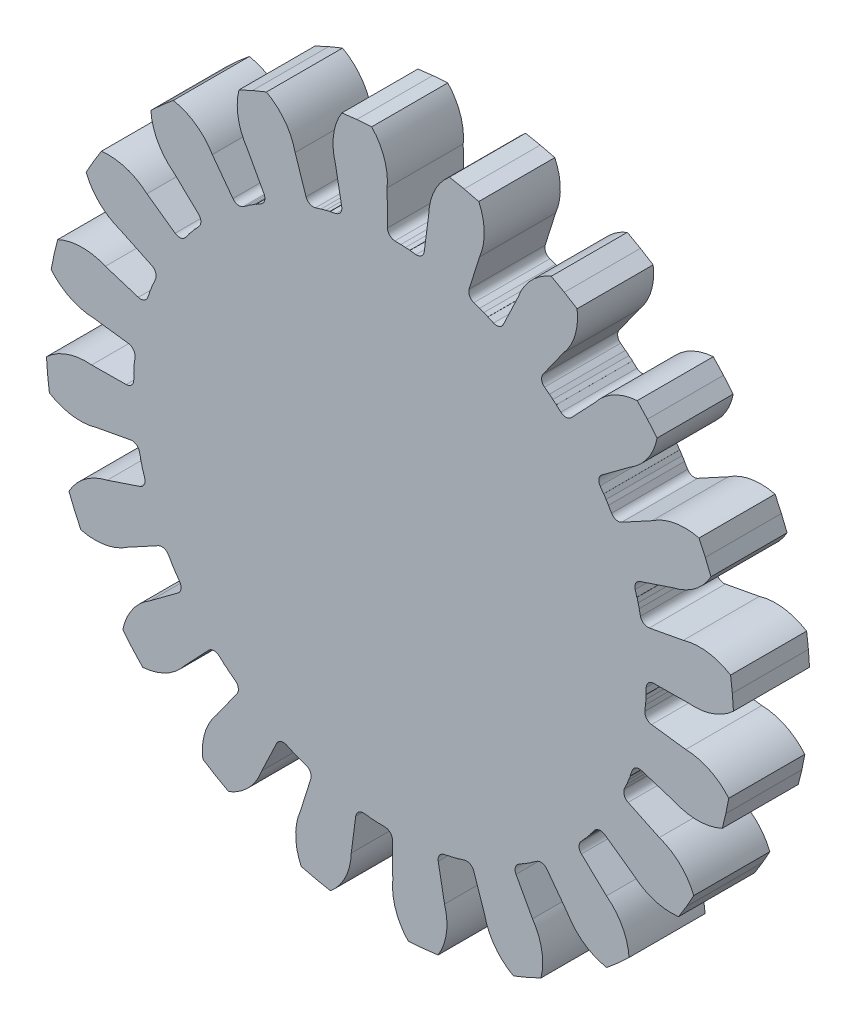
from build123d import *

# Parameters (mm, degrees)
BOSS_EXTRUDE1_DEPTH      = 10
FILLET2_R                = 1
CIRPATTERN1_COUNT        = 20
FILLET2_OF_CIRPATTERN1_R = 1


with BuildPart() as part:
    # Sketch1 → Boss-Extrude1 (new body)
    with BuildSketch(Plane.XY):
        with BuildLine():
            Line((38.885886089, -5.091685204), (33.432437269, -4.377615204))
            Line((33.432437269, -4.377615204), (33.686751056, -1.447128155))
            Line((33.686751056, -1.447128155), (0, 0))
            Line((0, 0), (31.160244407, -12.881403073))
            Line((31.160244407, -12.881403073), (32.164358522, -10.1165912))
            Line((32.164358522, -10.1165912), (37.410960246, -11.766794321))
            ThreePointArc((37.410960246, -11.766794321), (40.558227871, -12.393780689), (43.685256176, -11.672601527))
            Line((43.685256176, -11.672601527), (44.152829219, -9.755967686))
            Line((44.152829219, -9.755967686), (44.536354843, -7.820762805))
            ThreePointArc((44.536354843, -7.820762805), (42.004320563, -5.849162489), (38.885886089, -5.091685204))
        make_face()
    boss_extrude1 = extrude(amount=BOSS_EXTRUDE1_DEPTH)

    # Fillet2
    fillet2_edges = [part.edges().sort_by_distance(p)[0] for p in [
        (33.432437269, -4.377615204, 5),
        (32.164358522, -10.1165912, 5),
    ]]
    fillet(fillet2_edges, radius=FILLET2_R)

    # CirPattern1: Boss-Extrude1 ×20 about axis
    cirpattern1_axis = Axis((0, 0, 0), (0, 0, 1))
    for i in range(1, CIRPATTERN1_COUNT):
        add(boss_extrude1.rotate(cirpattern1_axis, i * 360 / CIRPATTERN1_COUNT))

    # Fillet2 of CirPattern1
    fillet2_of_cirpattern1_edges = [part.edges().sort_by_distance(p)[0] for p in [
        (33.148894813, 6.167831814, 5),
        (33.71632137, 0.317883413, 5),
        (29.620507571, 16.10952848, 5),
        (31.967895768, 10.721241383, 5),
        (23.19265867, 24.474312257, 5),
        (27.090229794, 20.075129547, 5),
        (14.494550745, 30.443379827, 5),
        (19.560783379, 27.463924159, 5),
        (4.377615204, 33.432437269, 5),
        (10.1165912, 32.164358522, 5),
        (-6.167831814, 33.148894813, 5),
        (-0.317883413, 33.71632137, 5),
        (-16.10952848, 29.620507571, 5),
        (-10.721241383, 31.967895768, 5),
        (-24.474312257, 23.19265867, 5),
        (-20.075129547, 27.090229794, 5),
        (-30.443379827, 14.494550745, 5),
        (-27.463924159, 19.560783379, 5),
        (-33.432437269, 4.377615204, 5),
        (-32.164358522, 10.1165912, 5),
        (-33.148894813, -6.167831814, 5),
        (-33.71632137, -0.317883413, 5),
        (-29.620507571, -16.10952848, 5),
        (-31.967895768, -10.721241383, 5),
        (-23.19265867, -24.474312257, 5),
        (-27.090229794, -20.075129547, 5),
        (-14.494550745, -30.443379827, 5),
        (-19.560783379, -27.463924159, 5),
        (-4.377615204, -33.432437269, 5),
        (-10.1165912, -32.164358522, 5),
        (6.167831814, -33.148894813, 5),
        (0.317883413, -33.71632137, 5),
        (16.10952848, -29.620507571, 5),
        (10.721241383, -31.967895768, 5),
        (24.474312257, -23.19265867, 5),
        (20.075129547, -27.090229794, 5),
        (30.443379827, -14.494550745, 5),
        (27.463924159, -19.560783379, 5),
    ]]
    fillet(fillet2_of_cirpattern1_edges, radius=FILLET2_OF_CIRPATTERN1_R)


solid = part.part
